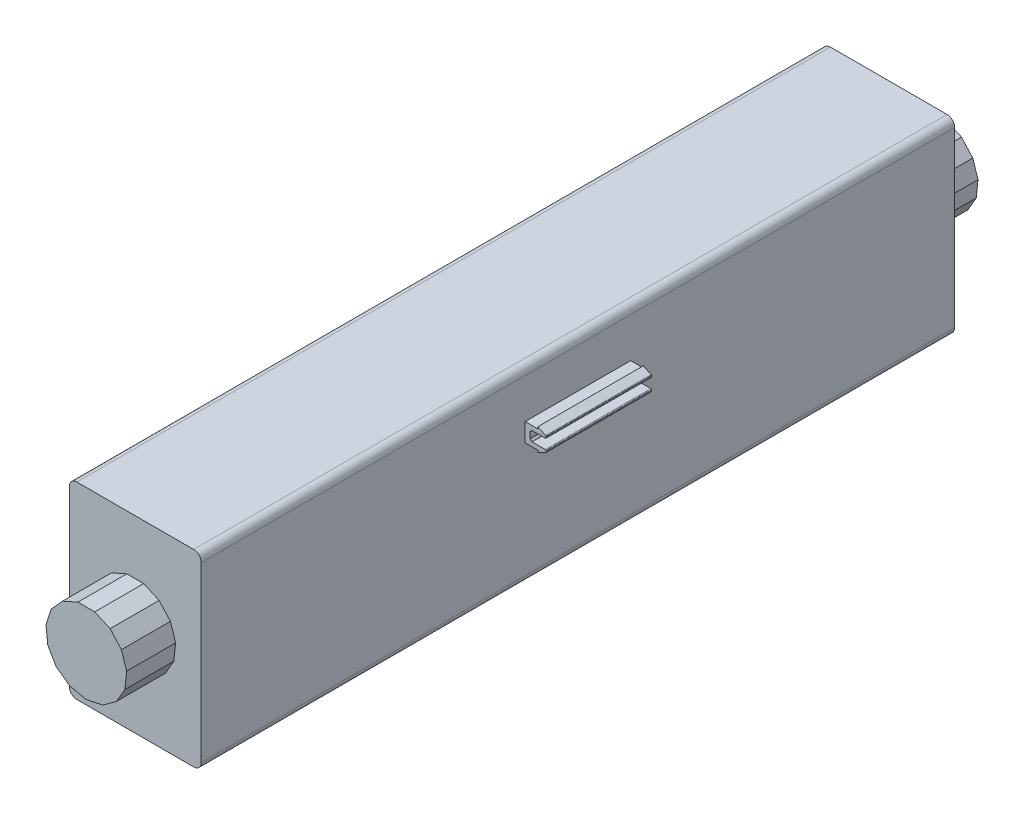
from build123d import *

# Parameters (mm, degrees)
BOSS_EXTRUDE6_DEPTH     = 13
SKETCH10_W              = 35
SKETCH10_H              = 50
BOSS_EXTRUDE7_DEPTH     = 200
BOSS_EXTRUDE8_DEPTH     = 13
BOSS_EXTRUDE10_DEPTH    = 200
FILLET2_R               = 0.2
FILLET3_R               = 0.2
SKETCH13_W              = 69.491392083
SKETCH13_H              = 95.024424652
SKETCH13_W_2            = 70.992171295
SKETCH13_H_2            = 120
CUT_EXTRUDE1_DEPTH      = 40
CUT_EXTRUDE1_DEPTH_BACK = 40
FILLET4_R               = 2


with BuildPart() as part:
    # Sketch9 → Boss-Extrude6 (new body)
    with BuildSketch(Plane(origin=(54.235591649, 0, 0), x_dir=(1, 0, 0), z_dir=(0, 0, 1))):
        Polygon((26.684813292, -242.858935562), (22.210553706, -242.858935562), (18.123114185, -244.678780887), (15.129250155, -248.003803746), (13.746627905, -252.259077482), (14.214315384, -256.708826606), (16.451445177, -260.583649071), (20.07119722, -263.213552871), (24.447683499, -264.143803746), (28.824169779, -263.213552871), (32.443921821, -260.583649071), (34.681051615, -256.708826606), (35.148739093, -252.259077482), (33.766116844, -248.003803746), (30.772252814, -244.678780887), align=None)
    extrude(amount=BOSS_EXTRUDE6_DEPTH)

    # Sketch10 → Boss-Extrude7 (add)
    with BuildSketch(Plane.XY.offset(13)):
        with Locations((78.683275149, -253.383803746)):
            Rectangle(SKETCH10_W, SKETCH10_H)
    extrude(amount=BOSS_EXTRUDE7_DEPTH)

    # Sketch11 → Boss-Extrude8 (add)
    with BuildSketch(Plane.XY.offset(213)):
        Polygon((78.683275149, -264.143803746), (83.059761428, -263.213552871), (86.679513471, -260.583649071), (88.916643264, -256.708826606), (89.384330743, -252.259077482), (88.001708493, -248.003803746), (85.007844463, -244.678780887), (80.920404942, -242.858935562), (76.446145356, -242.858935562), (72.358705834, -244.678780887), (69.364841804, -248.003803746), (67.982219555, -252.259077482), (68.449907033, -256.708826606), (70.687036827, -260.583649071), (74.306788869, -263.213552871), align=None)
    extrude(amount=BOSS_EXTRUDE8_DEPTH)

    # Sketch12 → Boss-Extrude10 (add)
    with BuildSketch(Plane.XY.offset(213)):
        Polygon((99.546985742, -240.476339651), (99.546985742, -240.976339651), (96.183275149, -240.976339651), (96.183275149, -245.876341177), (99.546985742, -245.876341177), (99.546985742, -246.376341177), (101.738909258, -245.329800525), (101.738909258, -244.726339651), (97.997187134, -244.726339651), (97.496982691, -244.234356535), (97.496982691, -242.626350386), (97.99698111, -242.126341177), (101.738909258, -242.126341177), (101.738909258, -241.524181899), align=None)
    extrude(amount=-BOSS_EXTRUDE10_DEPTH)

    # Fillet2
    fillet2_edges = [part.edges().sort_by_distance(p)[0] for p in [
        (101.738909258, -241.524181899, 113),
        (101.738909258, -242.126341177, 113),
        (97.99698111, -242.126341177, 113),
        (97.496982691, -242.626350386, 113),
        (97.496982691, -244.234356535, 113),
        (97.997187134, -244.726339651, 113),
        (101.738909258, -245.329800525, 113),
    ]]
    fillet(fillet2_edges, radius=FILLET2_R)

    # Fillet3
    fillet3_edges = [part.edges().sort_by_distance(p)[0] for p in [
        (101.738909258, -244.726339651, 113),
    ]]
    fillet(fillet3_edges, radius=FILLET3_R)

    # Sketch13 → Cut-Extrude1 (cut, two sides)
    with BuildSketch(Plane(origin=(0, -240.976339651, 0), x_dir=(1, 0, 0), z_dir=(0, 1, 0))) as cut_extrude1_sk:
        with Locations((130.928971191, -51.487787674)):
            Rectangle(SKETCH13_W, SKETCH13_H)
        with Locations((131.679360797, -187)):
            Rectangle(SKETCH13_W_2, SKETCH13_H_2)
    extrude(amount=CUT_EXTRUDE1_DEPTH, mode=Mode.SUBTRACT)
    extrude(cut_extrude1_sk.sketch, amount=-CUT_EXTRUDE1_DEPTH_BACK, mode=Mode.SUBTRACT)

    # Fillet4
    fillet4_edges = [part.edges().sort_by_distance(p)[0] for p in [
        (96.183275149, -278.383803746, 113),
        (96.183275149, -228.383803746, 113),
        (61.183275149, -228.383803746, 113),
        (61.183275149, -278.383803746, 113),
    ]]
    fillet(fillet4_edges, radius=FILLET4_R)


solid = part.part
